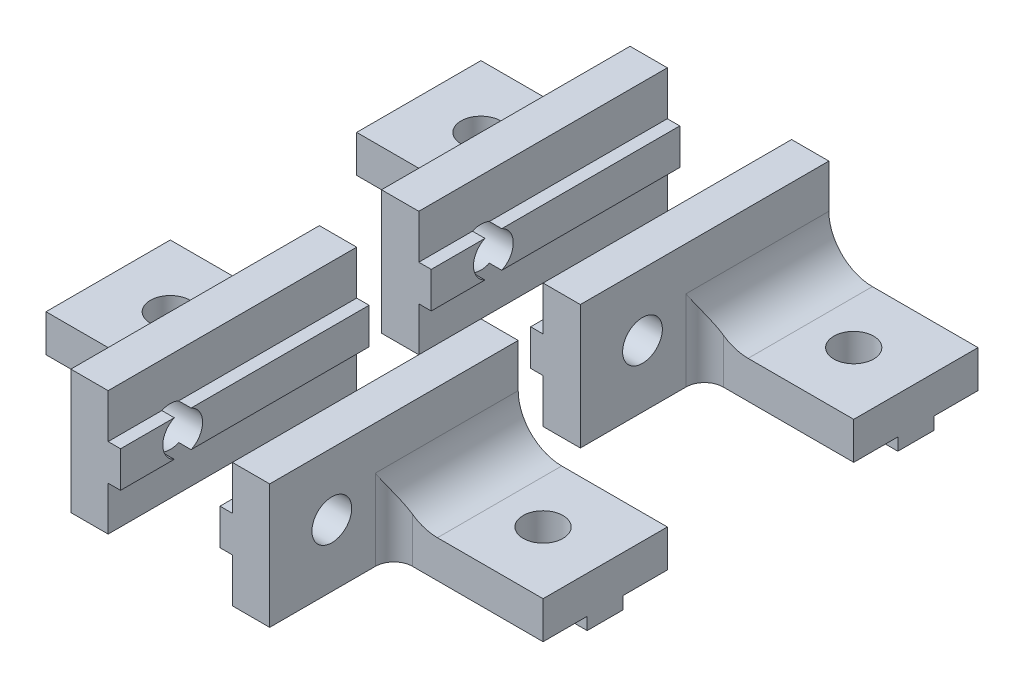
from build123d import *

# Parameters (mm, degrees)
MAIN_DEPTH                   = 20
ESQUISSE4_W                  = 20
ESQUISSE4_H                  = 2.9
VERTICALGUIDANCE_DEPTH       = 1
VERTICALHOLE_DEPTH           = 27.925824036
VERTICALHOLE_DEPTH_BACK      = 27.925824036
ESQUISSE2_R                  = 1.6
ESQUISSE5_W                  = 15
ESQUISSE5_H                  = 2.9
HORIZONTALGUIDANCE_DEPTH     = 1
HORIZONTALHOLE_DEPTH         = 26.961510049
HORIZONTALHOLE_DEPTH_BACK    = 26.961510049
ESQUISSE3_R                  = 1.6
ENL_V_MAT_EXTRU_4_DEPTH      = 26.961510049
ENL_V_MAT_EXTRU_4_DEPTH_BACK = 26.961510049
ESQUISSE9_W                  = 12
ESQUISSE9_H                  = 10
CONG_2_R                     = 1.5
R_P_TITION_LIN_AIRE1_COUNT   = 2
R_P_TITION_LIN_AIRE1_PITCH   = 25


with BuildPart() as part:
    # Esquisse1 → Main (new body)
    with BuildSketch(Plane.XY):
        with BuildLine():
            Line((0, 0), (15, 0))
            Line((15, 0), (15, 3))
            Line((15, 3), (6.5, 3))
            ThreePointArc((6.5, 3), (4.025126266, 4.025126266), (3, 6.5))
            Line((3, 6.5), (3, 10))
            Line((3, 10), (0, 10))
            Line((0, 10), (0, 0))
        make_face()
    extrude(amount=MAIN_DEPTH)

    # Esquisse4 → VerticalGuidance (add)
    with BuildSketch(Plane.ZY):
        with Locations((10, 5)):
            Rectangle(ESQUISSE4_W, ESQUISSE4_H)
    extrude(amount=VERTICALGUIDANCE_DEPTH)

    # Esquisse2 → VerticalHole (cut, two sides: drawn at the far end of the back side and taken through both)
    with BuildSketch(Plane.ZY.offset(-VERTICALHOLE_DEPTH_BACK)):
        with Locations((15, 5)):
            Circle(ESQUISSE2_R)
    extrude(amount=VERTICALHOLE_DEPTH + VERTICALHOLE_DEPTH_BACK, mode=Mode.SUBTRACT)

    # Esquisse5 → HorizontalGuidance (add)
    with BuildSketch(Plane(origin=(0, 0, 0), x_dir=(-1, 0, 0), z_dir=(0, -1, 0))):
        with Locations((-7.5, -5)):
            Rectangle(ESQUISSE5_W, ESQUISSE5_H)
    extrude(amount=HORIZONTALGUIDANCE_DEPTH)

    # Esquisse3 → HorizontalHole (cut, two sides: drawn at the far end of the back side and taken through both)
    with BuildSketch(Plane.XZ.offset(-3).offset(-HORIZONTALHOLE_DEPTH_BACK)):
        with Locations((10, 5)):
            Circle(ESQUISSE3_R)
    extrude(amount=HORIZONTALHOLE_DEPTH + HORIZONTALHOLE_DEPTH_BACK, mode=Mode.SUBTRACT)

    # Esquisse9 → Enlèv. mat.-Extru.4 (cut, two sides: drawn at the far end of the back side and taken through both)
    with BuildSketch(Plane(origin=(0, 3, 0), x_dir=(1, 0, 0), z_dir=(0, 1, 0)).offset(-ENL_V_MAT_EXTRU_4_DEPTH_BACK)):
        with Locations((9, -15)):
            Rectangle(ESQUISSE9_W, ESQUISSE9_H)
    extrude(amount=ENL_V_MAT_EXTRU_4_DEPTH + ENL_V_MAT_EXTRU_4_DEPTH_BACK, mode=Mode.SUBTRACT)

    # Congé2
    cong_2_edges = [part.edges().sort_by_distance(p)[0] for p in [
        (3, 3.25, 10),
    ]]
    fillet(cong_2_edges, radius=CONG_2_R)


with BuildPart() as r_p_tition_lin_aire1_1:
    # Répétition linéaire1: pattern copy
    add(part.part.moved(Location(Vector(0, 0, 1) * (1 * R_P_TITION_LIN_AIRE1_PITCH))))


with BuildPart() as body_3:
    # Symétrie3: mirrored copy
    add(r_p_tition_lin_aire1_1.part.mirror(Plane(origin=(-5, 0, 0), x_dir=(0, 0, 1), z_dir=(1, 0, 0))))


with BuildPart() as body_4:
    # Sym_trie3 2: mirrored copy
    add(part.part.mirror(Plane(origin=(-5, 0, 0), x_dir=(0, 0, 1), z_dir=(1, 0, 0))))


solid = Compound([part.part, r_p_tition_lin_aire1_1.part, body_3.part, body_4.part])
